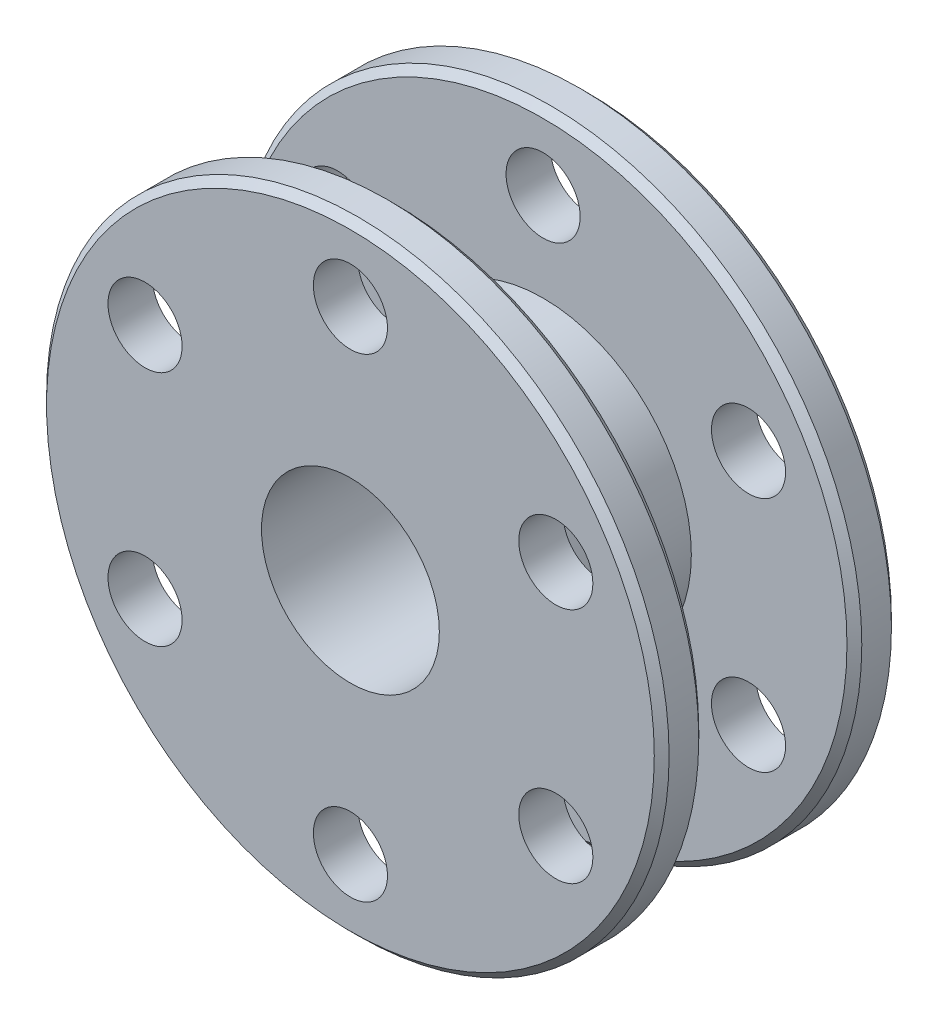
from build123d import *

# Parameters (mm, degrees)
BOSS_EXTRUDE1_DEPTH      = 4
BOSS_EXTRUDE1_DEPTH_BACK = 4
SKETCH1_R                = 10.5
SKETCH2_R                = 3
CUT_EXTRUDE1_DEPTH       = 10
CHAMFER1_SIZE            = 0.25
CHAMFER2_SIZE            = 0.25
CUT_EXTRUDE2_START       = -1.5
SKETCH3_OUTSIDE_W        = 29.152
SKETCH3_OUTSIDE_H        = 29.152
SKETCH3_OUTSIDE_R        = 5
CUT_EXTRUDE2_DEPTH       = 5
CHAMFER3_SIZE            = 0.25
CUT_EXTRUDE3_DEPTH       = 17.867127793
CUT_EXTRUDE3_DEPTH_BACK  = 17.867127793
SKETCH4_R                = 1.25


with BuildPart() as part:
    # Sketch1 → Boss-Extrude1 (new, two sides: drawn at the far end of the back side and taken through both)
    with BuildSketch(Plane.XY.offset(-BOSS_EXTRUDE1_DEPTH_BACK)):
        Circle(SKETCH1_R)
    extrude(amount=BOSS_EXTRUDE1_DEPTH + BOSS_EXTRUDE1_DEPTH_BACK)

    # Sketch2 → Cut-Extrude1 (cut)
    with BuildSketch(Plane.XY.offset(4)):
        Circle(SKETCH2_R)
    extrude(amount=-CUT_EXTRUDE1_DEPTH, mode=Mode.SUBTRACT)

    # Chamfer1
    chamfer1_edges = [part.edges().sort_by_distance(p)[0] for p in [
        (-10.5, 0, 4),
    ]]
    chamfer(chamfer1_edges, length=CHAMFER1_SIZE)

    # Chamfer2
    chamfer2_edges = [part.edges().sort_by_distance(p)[0] for p in [
        (-10.5, 0, -4),
    ]]
    chamfer(chamfer2_edges, length=CHAMFER2_SIZE)

    # Sketch3 outside → Cut-Extrude2 (cut)
    with BuildSketch(Plane.XY.offset(4).offset(CUT_EXTRUDE2_START)):
        Rectangle(SKETCH3_OUTSIDE_W, SKETCH3_OUTSIDE_H)
        Circle(SKETCH3_OUTSIDE_R, mode=Mode.SUBTRACT)
    extrude(amount=-CUT_EXTRUDE2_DEPTH, mode=Mode.SUBTRACT)

    # Chamfer3
    chamfer3_edges = [part.edges().sort_by_distance(p)[0] for p in [
        (-10.5, 0, -2.5),
        (-10.5, 0, 2.5),
    ]]
    chamfer(chamfer3_edges, length=CHAMFER3_SIZE)

    # Sketch4 → Cut-Extrude3 (cut, two sides: drawn at the far end of the back side and taken through both)
    with BuildSketch(Plane.XY.offset(4).offset(-CUT_EXTRUDE3_DEPTH_BACK)):
        with Locations((0, 8)):
            Circle(SKETCH4_R)
        with Locations((6.92820323, 4)):
            Circle(SKETCH4_R)
        with Locations((6.92820323, -4)):
            Circle(SKETCH4_R)
        with Locations((0, -8)):
            Circle(SKETCH4_R)
        with Locations((-6.92820323, -4)):
            Circle(SKETCH4_R)
        with Locations((-6.92820323, 4)):
            Circle(SKETCH4_R)
    extrude(amount=CUT_EXTRUDE3_DEPTH + CUT_EXTRUDE3_DEPTH_BACK, mode=Mode.SUBTRACT)


solid = part.part
